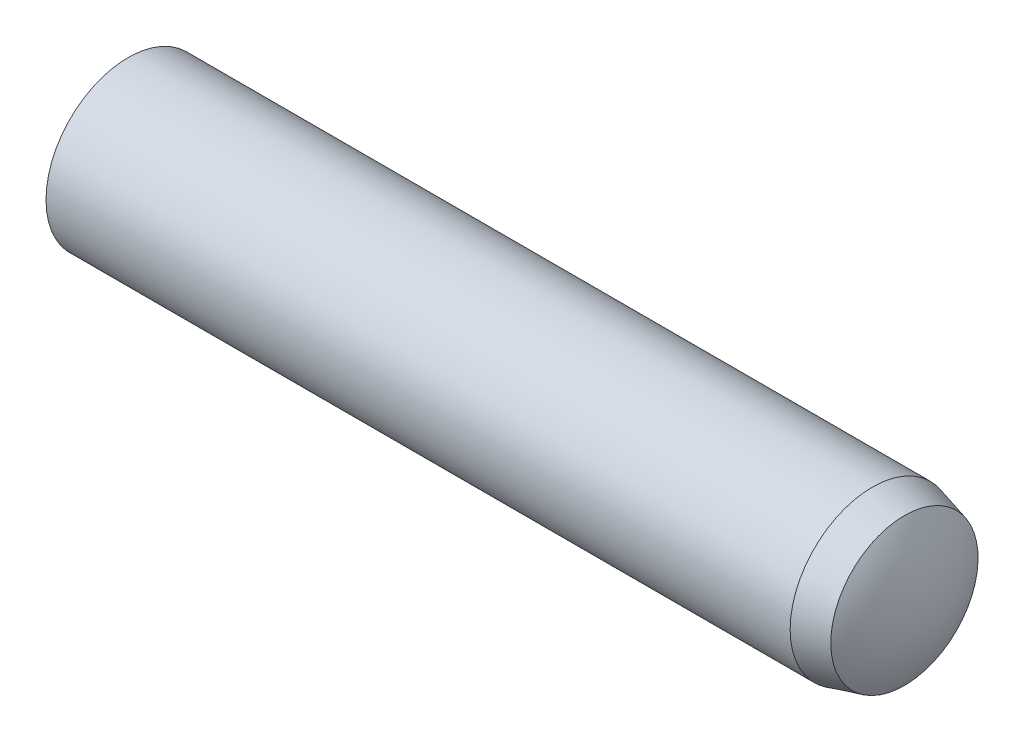
from build123d import *

# Parameters (mm, degrees)
SKETCH2_R           = 1
EXTRUDE1_DEPTH      = 5
EXTRUDE1_DEPTH_BACK = 5


with BuildPart() as part:
    # Sketch2 → Extrude1 (new body, two sides)
    with BuildSketch(Plane(origin=(0, 0, 0), x_dir=(0, 0, -1), z_dir=(1, 0, 0))) as extrude1_sk:
        Circle(SKETCH2_R)
    extrude(amount=EXTRUDE1_DEPTH)
    extrude(extrude1_sk.sketch, amount=-EXTRUDE1_DEPTH_BACK)

    # Sketch5 → Cut-Revolve1 (revolve, cut)
    with BuildSketch(Plane.XY):
        with BuildLine():
            Line((4.35, 1), (4.35, 1.5))
            Line((4.35, 1.5), (5.5, 1.5))
            Line((5.5, 1.5), (5.5, 0))
            Line((5.5, 0), (5, 0))
            ThreePointArc((5, 0), (4.933685026, 0.46624026), (4.74, 0.895499815))
            Line((4.74, 0.895499815), (4.35, 1))
        make_face()
        with BuildLine():
            Line((-4.7, 1), (-4.7, 1.5))
            Line((-4.7, 1.5), (-5.5, 1.5))
            Line((-5.5, 1.5), (-5.5, 0))
            Line((-5.5, 0), (-5, 0))
            ThreePointArc((-5, 0), (-4.923384418, 0.522015325), (-4.7, 1))
        make_face()
    revolve(axis=Axis((-5, 0, 0), (1, 0, 0)), mode=Mode.SUBTRACT)


solid = part.part
